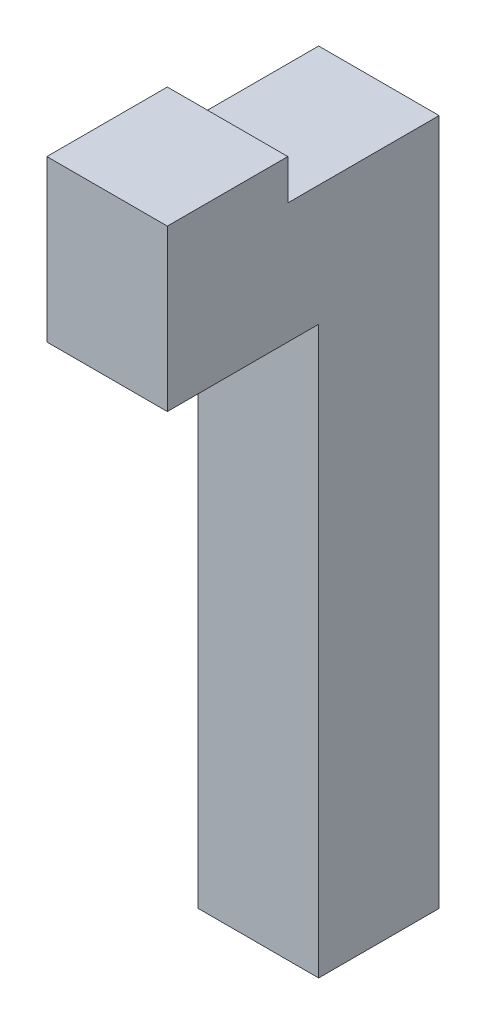
from build123d import *

# Parameters (mm, degrees)
SKETCH1_W           = 30
SKETCH1_H           = 30
BOSS_EXTRUDE1_DEPTH = 171
SKETCH2_R           = 10
CUT_EXTRUDE1_DEPTH  = 10
SKETCH3_W           = 30
SKETCH3_H           = 30
BOSS_EXTRUDE2_DEPTH = 37.6839
SKETCH5_W           = 30
SKETCH5_H           = 30
BOSS_EXTRUDE3_DEPTH = 10


with BuildPart() as part:
    # Sketch1 → Boss-Extrude1 (new body)
    with BuildSketch(Plane(origin=(0, 0, 0), x_dir=(1, 0, 0), z_dir=(0, 1, 0))):
        Rectangle(SKETCH1_W, SKETCH1_H)
    extrude(amount=BOSS_EXTRUDE1_DEPTH)

    # Sketch2 → Cut-Extrude1 (cut)
    with BuildSketch(Plane.XZ):
        Circle(SKETCH2_R)
    extrude(amount=-CUT_EXTRUDE1_DEPTH, mode=Mode.SUBTRACT)

    # Sketch3 → Boss-Extrude2 (add)
    with BuildSketch(Plane.XY.offset(15)):
        with Locations((0, 156)):
            Rectangle(SKETCH3_W, SKETCH3_H)
    extrude(amount=BOSS_EXTRUDE2_DEPTH)

    # Sketch5 → Boss-Extrude3 (add)
    with BuildSketch(Plane(origin=(0, 171, 0), x_dir=(1, 0, 0), z_dir=(0, 1, 0))):
        with Locations((0, -37.6839)):
            Rectangle(SKETCH5_W, SKETCH5_H)
    extrude(amount=BOSS_EXTRUDE3_DEPTH)


solid = part.part
